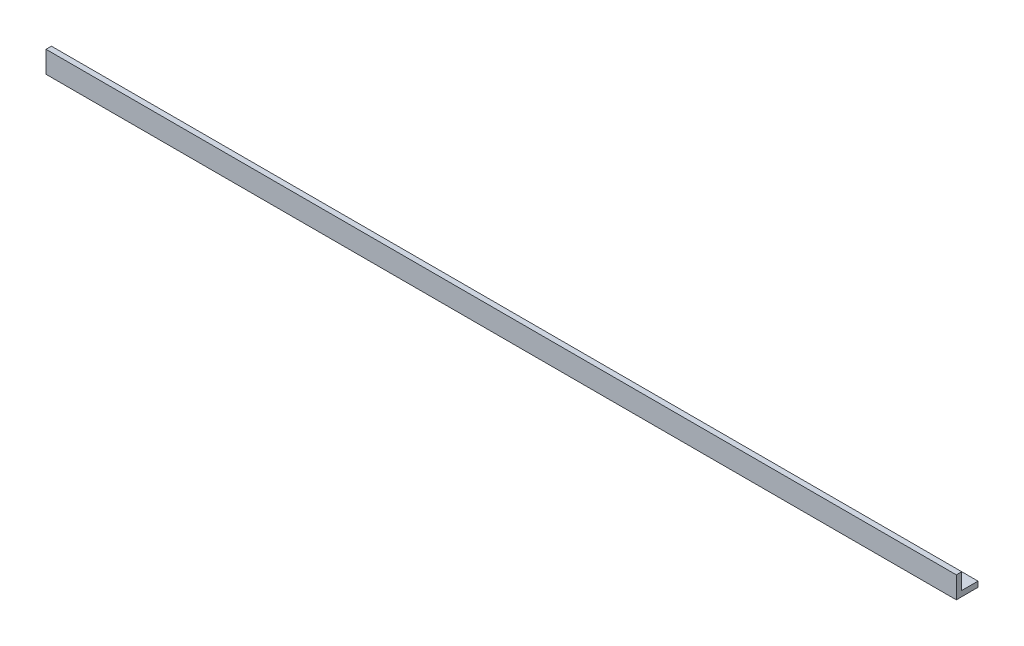
from build123d import *

# Parameters (mm, degrees)
BOSS_EXTRUDE1_DEPTH      = 533.4
BOSS_EXTRUDE1_DEPTH_BACK = 533.4


with BuildPart() as part:
    # Sketch1 → Boss-Extrude1 (new body, two sides)
    with BuildSketch(Plane(origin=(0, 0, 0), x_dir=(0, 0, -1), z_dir=(1, 0, 0))) as boss_extrude1_sk:
        Polygon((25.4, 6.35), (25.4, 0), (0, 0), (0, 25.4), (6.35, 25.4), (6.35, 6.35), align=None)
    extrude(amount=BOSS_EXTRUDE1_DEPTH)
    extrude(boss_extrude1_sk.sketch, amount=-BOSS_EXTRUDE1_DEPTH_BACK)


solid = part.part
